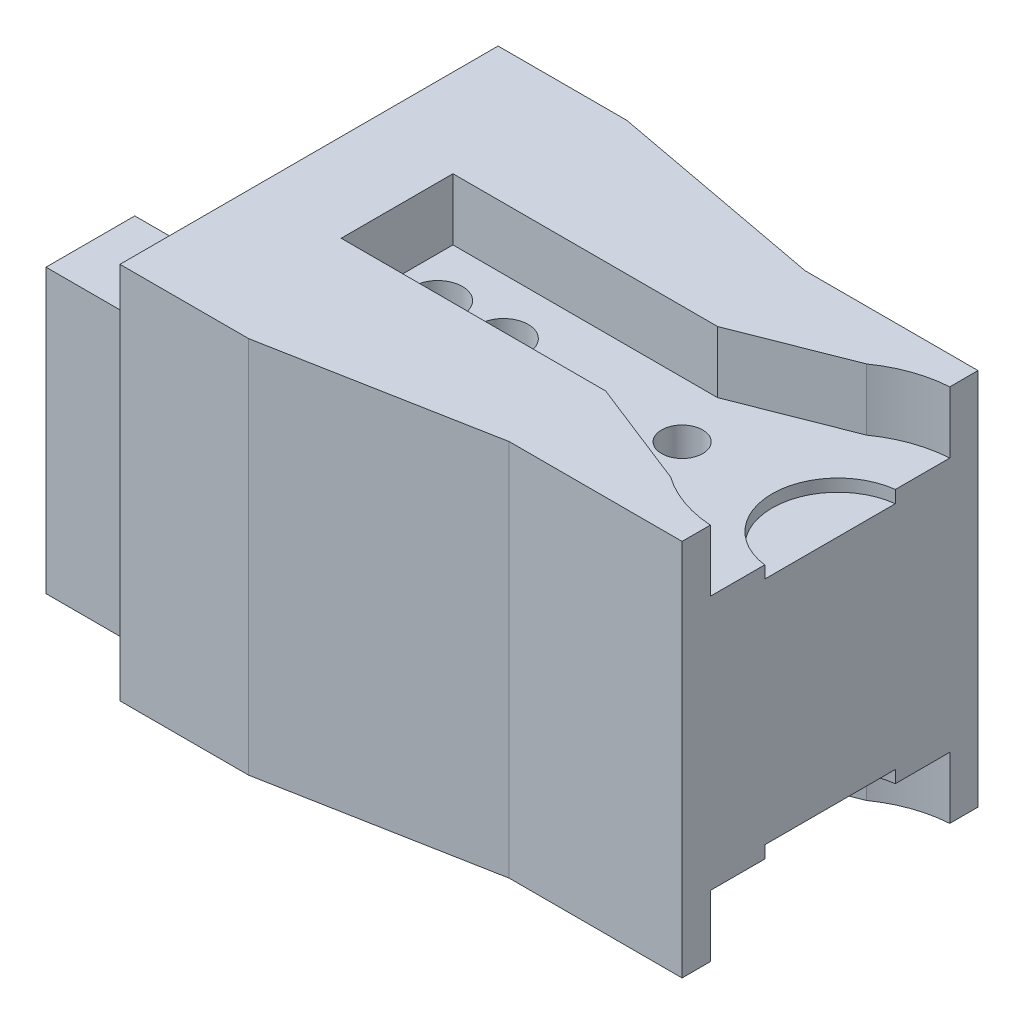
from build123d import *

# Parameters (mm, degrees)
BOSS_EXTRUDE1_DEPTH = 11.5
SKETCH1_13_R        = 1.5
SKETCH1_13_R_2      = 1.25
BOSS_EXTRUDE2_DEPTH = 7.75
BOSS_EXTRUDE3_DEPTH = 7
SKETCH2_R           = 1.5
BOSS_EXTRUDE4_DEPTH = 5


with BuildPart() as part:
    # Sketch1 → Boss-Extrude1 (new, symmetric)
    with BuildSketch(Plane(origin=(0, 0, 0), x_dir=(1, 0, 0), z_dir=(0, 1, 0))):
        with BuildLine():
            Line((6.824314586, 7.284360201), (6.824314586, 9.00020274))
            Line((6.824314586, 9.00020274), (-3.690467309, 9.00020274))
            Line((-3.690467309, 9.00020274), (-17.038497557, 11.5))
            Line((-17.038497557, 11.5), (-24.867971487, 11.5))
            Line((-24.867971487, 11.5), (-24.867971487, -11.5))
            Line((-24.867971487, -11.5), (-17.038497557, -11.5))
            Line((-17.038497557, -11.5), (-3.690467309, -9.00020274))
            Line((-3.690467309, -9.00020274), (6.824314586, -9.00020274))
            Line((6.824314586, -9.00020274), (6.824314586, -7.284360201))
            ThreePointArc((6.824314586, -7.284360201), (4.861171432, -6.879883717), (3.082035449, -5.956732906))
            Line((3.082035449, -5.956732906), (-3.422402494, -3.4))
            Line((-3.422402494, -3.4), (-19.513448301, -3.4))
            Line((-19.513448301, -3.4), (-19.513448301, 3.4))
            Line((-19.513448301, 3.4), (-3.422402494, 3.4))
            Line((-3.422402494, 3.4), (3.082035449, 5.956732906))
            ThreePointArc((3.082035449, 5.956732906), (4.861171432, 6.879883717), (6.824314586, 7.284360201))
        make_face()
    extrude(amount=BOSS_EXTRUDE1_DEPTH, both=True)

    # Sketch1_13 → Boss-Extrude2 (add, symmetric)
    with BuildSketch(Plane(origin=(0, 0, 0), x_dir=(1, 0, 0), z_dir=(0, 1, 0))):
        with BuildLine():
            Line((6.824314586, 3.971385595), (6.824314586, 7.284360201))
            ThreePointArc((6.824314586, 7.284360201), (4.861171432, 6.879883717), (3.082035449, 5.956732906))
            Line((3.082035449, 5.956732906), (-3.422402494, 3.4))
            Line((-3.422402494, 3.4), (-19.513448301, 3.4))
            Line((-19.513448301, 3.4), (-19.513448301, -3.4))
            Line((-19.513448301, -3.4), (-3.422402494, -3.4))
            Line((-3.422402494, -3.4), (3.082035449, -5.956732906))
            ThreePointArc((3.082035449, -5.956732906), (4.861171432, -6.879883717), (6.824314586, -7.284360201))
            Line((6.824314586, -7.284360201), (6.824314586, -3.971385595))
            ThreePointArc((6.824314586, -3.971385595), (3.301909035, 0), (6.824314586, 3.971385595))
        make_face()
        with Locations((-17.038497557, 0)):
            Circle(SKETCH1_13_R, mode=Mode.SUBTRACT)
        with Locations((-13.038497557, 0)):
            Circle(SKETCH1_13_R, mode=Mode.SUBTRACT)
        with Locations((-2.172402494, 0)):
            Circle(SKETCH1_13_R_2, mode=Mode.SUBTRACT)
    extrude(amount=BOSS_EXTRUDE2_DEPTH, both=True)

    # Sketch1_14 → Boss-Extrude3 (add, symmetric)
    with BuildSketch(Plane(origin=(0, 0, 0), x_dir=(1, 0, 0), z_dir=(0, 1, 0))):
        with BuildLine():
            Line((6.824314586, -3.971385595), (6.824314586, 3.971385595))
            ThreePointArc((6.824314586, 3.971385595), (3.301909035, 0), (6.824314586, -3.971385595))
        make_face()
    extrude(amount=BOSS_EXTRUDE3_DEPTH, both=True)

    # Sketch2 → Boss-Extrude4 (add)
    with BuildSketch(Plane.ZY.offset(24.867971487)):
        Polygon((5.6, 5.7), (0.8, 5.7), (0.8, 5.69251999), (-10.999928788, 5.69251999), (-10.999928788, -5.69251999), (0.8, -5.69251999), (0.8, -5.7), (5.6, -5.7), (5.6, -8.6), (11, -8.6), (11, 8.6), (5.6, 8.6), align=None)
        with Locations((-5.3, 0)):
            Circle(SKETCH2_R, mode=Mode.SUBTRACT)
    extrude(amount=BOSS_EXTRUDE4_DEPTH)


solid = part.part
